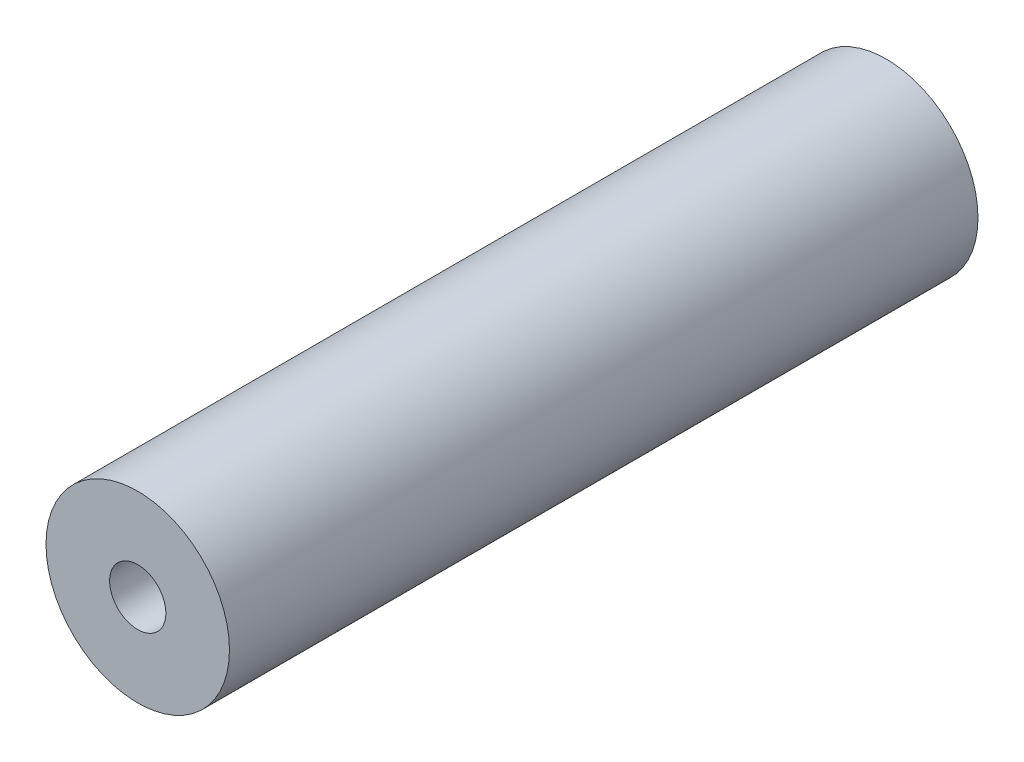
from build123d import *

# Parameters (mm, degrees)
SKETCH1_R                   = 9.779
BOSS_EXTRUDE1_DEPTH         = 92.6
SKETCH2_R                   = 3.4925
CUT_EXTRUDE1_DEPTH          = 30.7815
FILLET1_R                   = 0.254
FILLET2_R                   = 0.254
SKETCH3_R                   = 11.060223395
CUT_EXTRUDE2_DEPTH          = 12.8016
M6_TAPPED_HOLE1_D           = 5
M6_TAPPED_HOLE1_DEPTH       = 8.497848452
M6_TAPPED_HOLE1_CBORE_D     = 6
M6_TAPPED_HOLE1_CBORE_DEPTH = 7
M6_TAPPED_HOLE1_TIP         = 1.502151548


with BuildPart() as part:
    # Sketch1 → Boss-Extrude1 (new body)
    with BuildSketch(Plane.XY):
        with Locations((20.0025, 19.685)):
            Circle(SKETCH1_R)
    extrude(amount=BOSS_EXTRUDE1_DEPTH)

    # Sketch2 → Cut-Extrude1 (cut, through all)
    with BuildSketch(Plane(origin=(0, 0, 0), x_dir=(0, 0, -1), z_dir=(1, 0, 0))):
        with Locations((-83.583, 19.685)):
            Circle(SKETCH2_R)
    extrude(amount=CUT_EXTRUDE1_DEPTH, mode=Mode.SUBTRACT)

    # Fillet1
    fillet1_edges = [part.edges().sort_by_distance(p)[0] for p in [
        (29.136572736, 23.1775, 83.583),
        (10.2235, 19.685, 87.075500001),
    ]]
    fillet(fillet1_edges, radius=FILLET1_R)

    # Fillet2
    fillet2_edges = [part.edges().sort_by_distance(p)[0] for p in [
        (10.2235, 19.685, 92.6),
    ]]
    fillet(fillet2_edges, radius=FILLET2_R)

    # Sketch3 → Cut-Extrude2 (cut)
    with BuildSketch(Plane.XY.offset(92.6)):
        with Locations((20.0025, 19.685)):
            Circle(SKETCH3_R)
    extrude(amount=-CUT_EXTRUDE2_DEPTH, mode=Mode.SUBTRACT)

    # M6 Tapped Hole1
    with Locations(Plane(origin=(20.0025, 19.685, 79.7984), x_dir=(1, 0, 0), z_dir=(0, 0, 1))):
        with Locations((0, 0)):
            CounterBoreHole(M6_TAPPED_HOLE1_D / 2, M6_TAPPED_HOLE1_CBORE_D / 2, M6_TAPPED_HOLE1_CBORE_DEPTH, depth=M6_TAPPED_HOLE1_DEPTH)
            with Locations((0, 0, -(M6_TAPPED_HOLE1_DEPTH + M6_TAPPED_HOLE1_TIP / 2))):  # 118° drill point
                Cone(0, M6_TAPPED_HOLE1_D / 2, M6_TAPPED_HOLE1_TIP, mode=Mode.SUBTRACT)


solid = part.part
